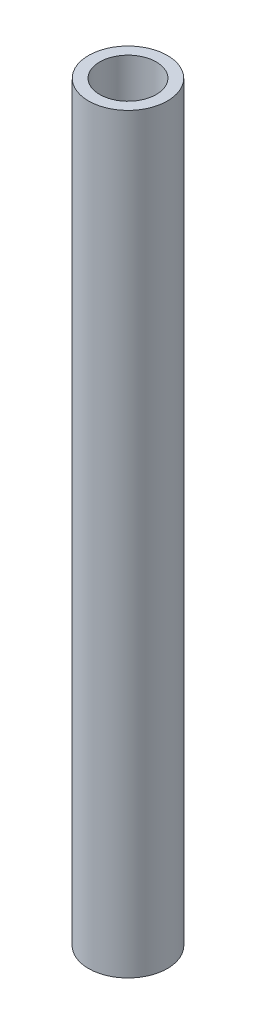
from build123d import *

# Parameters (mm, degrees)
SKETCH1_R           = 10.668
SKETCH1_R_2         = 7.6454
BOSS_EXTRUDE1_DEPTH = 203.2


with BuildPart() as part:
    # Sketch1 → Boss-Extrude1 (new body)
    with BuildSketch(Plane(origin=(0, 0, 0), x_dir=(1, 0, 0), z_dir=(0, 1, 0))):
        Circle(SKETCH1_R)
        Circle(SKETCH1_R_2, mode=Mode.SUBTRACT)
    extrude(amount=BOSS_EXTRUDE1_DEPTH)


solid = part.part
